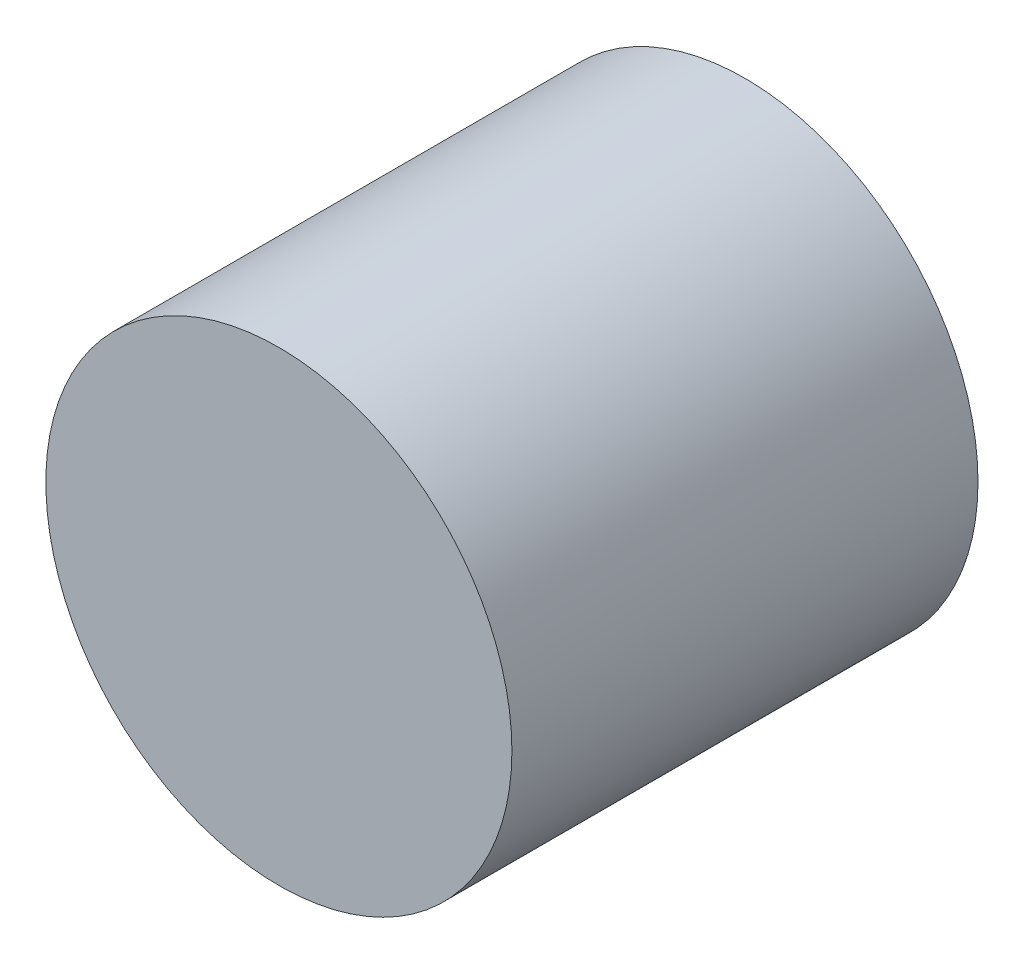
from build123d import *

# Parameters (mm, degrees)
SKETCH_1_R      = 0.5
EXTRUDE_1_DEPTH = 1


with BuildPart() as part:
    # 草图1 → 凸台-拉伸1 (new body)
    with BuildSketch(Plane.XY):
        Circle(SKETCH_1_R)
    extrude(amount=EXTRUDE_1_DEPTH)


solid = part.part
